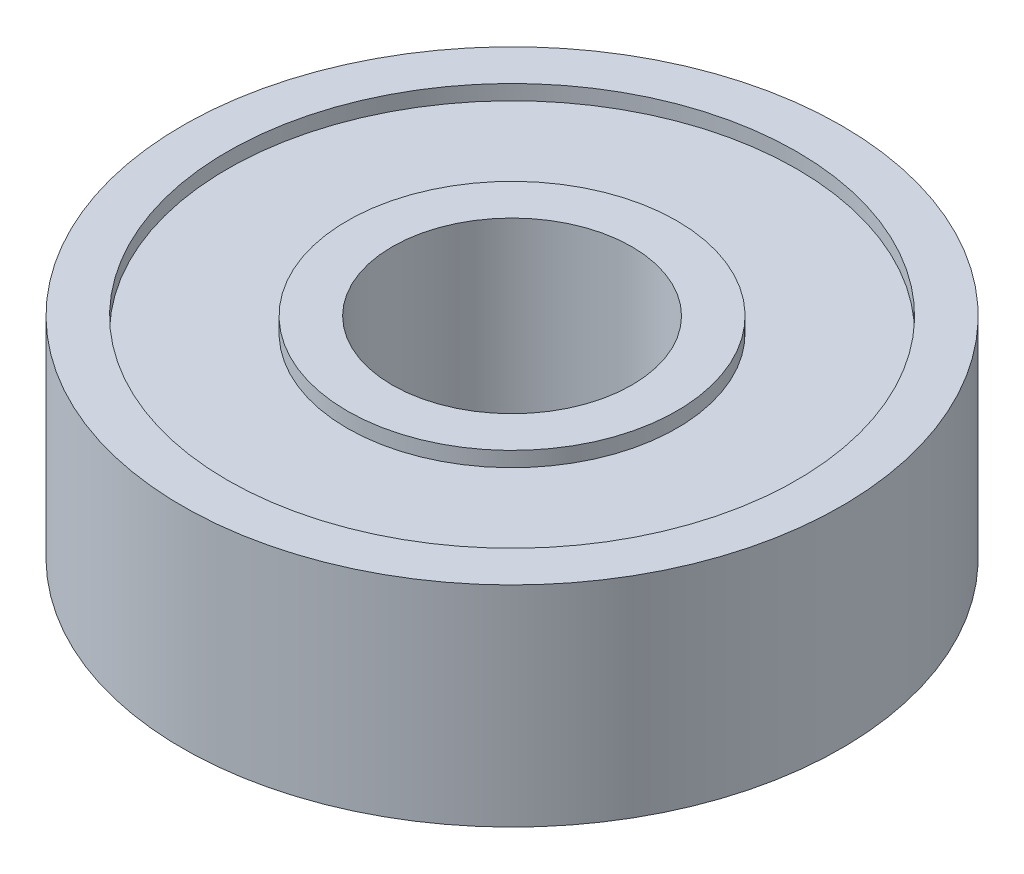
from build123d import *

# Parameters (mm, degrees)
SKETCH1_W   = 1.5
SKETCH1_H   = 7
SKETCH1_W_2 = 4
SKETCH1_H_2 = 6


with BuildPart() as part:
    # Sketch1 → Revolve1 (revolve)
    with BuildSketch(Plane.XY):
        with Locations((-10.25, 0)):
            Rectangle(SKETCH1_W, SKETCH1_H)
        with Locations((-7.5, 0)):
            Rectangle(SKETCH1_W_2, SKETCH1_H_2)
        with Locations((-4.75, 0)):
            Rectangle(SKETCH1_W, SKETCH1_H)
    revolve(axis=Axis((0, -3.362712124, 0), (0, 1, 0)))


solid = part.part
